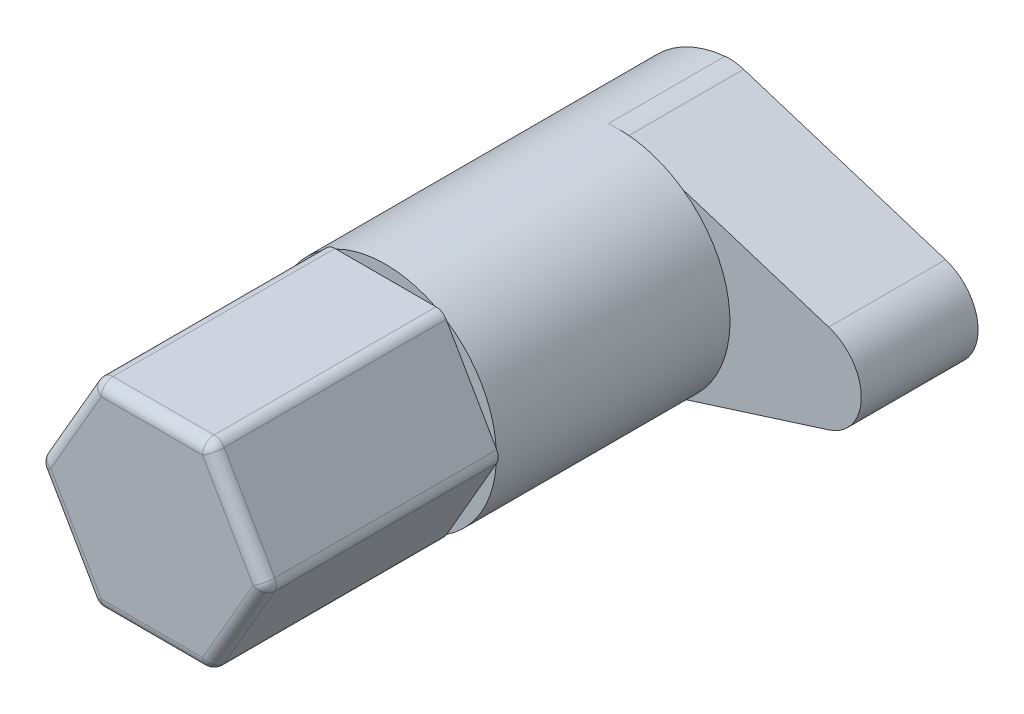
from build123d import *

# Parameters (mm, degrees)
BOSS_EXTRUDE1_DEPTH = 10
FILLET1_R           = 0.5
SKETCH2_R           = 4.75
BOSS_EXTRUDE2_DEPTH = 10
BOSS_EXTRUDE3_DEPTH = 5
FILLET2_R           = 2


with BuildPart() as part:
    # Sketch1 → Boss-Extrude1 (new body)
    with BuildSketch(Plane.XY):
        Polygon((2.453738644, -4.25), (4.907477288, 0), (2.453738644, 4.25), (-2.453738644, 4.25), (-4.907477288, 0), (-2.453738644, -4.25), align=None)
    extrude(amount=BOSS_EXTRUDE1_DEPTH)

    # Fillet1
    fillet1_edges = [part.edges().sort_by_distance(p)[0] for p in [
        (-2.453738644, -4.25, 5),
        (-4.907477288, 0, 5),
        (-2.453738644, 4.25, 5),
        (2.453738644, 4.25, 5),
        (4.907477288, 0, 5),
        (2.453738644, -4.25, 5),
        (3.680607966, 2.125, 10),
        (0, 4.25, 10),
        (-3.680607966, 2.125, 10),
        (-3.680607966, -2.125, 10),
        (0, -4.25, 10),
        (3.680607966, -2.125, 10),
    ]]
    fillet(fillet1_edges, radius=FILLET1_R)

    # Sketch2 → Boss-Extrude2 (add)
    with BuildSketch(Plane(origin=(0, 0, 0), x_dir=(-1, 0, 0), z_dir=(0, 0, -1))):
        with Locations(Location((0, 0, 0), (0, 0, 176.525352017))):
            Circle(SKETCH2_R)
    extrude(amount=BOSS_EXTRUDE2_DEPTH)

    # Sketch3 → Boss-Extrude3 (add)
    with BuildSketch(Plane(origin=(0, 0, -10), x_dir=(-1, 0, 0), z_dir=(0, 0, -1))):
        with BuildLine():
            Line((0, 4.75), (-15, 0))
            Line((-15, 0), (0, -4.75))
            ThreePointArc((0, -4.75), (4.75, 0), (0, 4.75))
        make_face()
    extrude(amount=BOSS_EXTRUDE3_DEPTH)

    # Fillet2
    fillet2_edges = [part.edges().sort_by_distance(p)[0] for p in [
        (0, -4.75, -12.5),
        (0, 4.75, -12.5),
        (15, 0, -12.5),
    ]]
    fillet(fillet2_edges, radius=FILLET2_R)


solid = part.part
